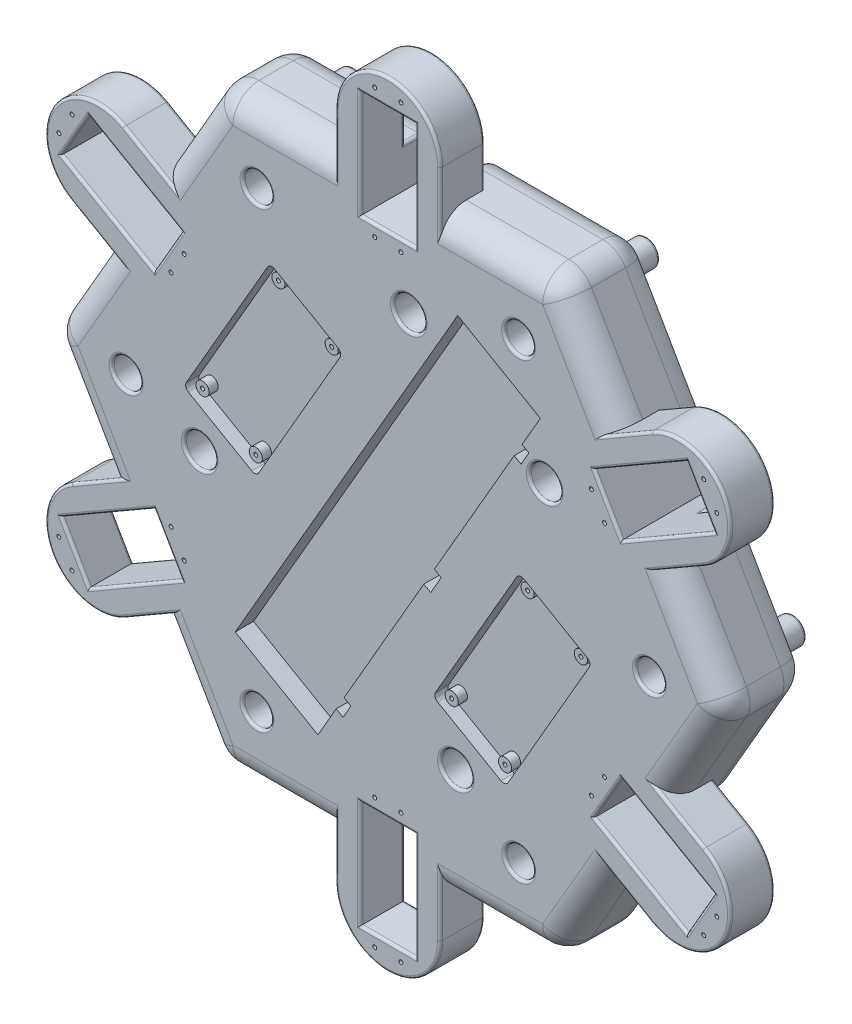
from build123d import *

# Parameters (mm, degrees)
MBODY_DEPTH              = 33
BOTTOMFLOOR_R            = 4.99999999999995
BOTTOMFLOOR_R_2          = 5.000000000000004
BOTTOMFLOOR_R_3          = 4.999999999999997
BOTTOMFLOOR_R_4          = 5.000000000000003
BOTTOMFLOOR_R_5          = 5
BODYBASE_DEPTH           = 10
SERVOCIRCLE_DEPTH        = 17
BBCUT_DEPTH              = 7
PCACUT_DEPTH             = 5
SKETCH10_R               = 2.4999999999999947
SKETCH10_R_2             = 0.7499999999999986
SKETCH10_R_3             = 2.499999999999995
SKETCH10_R_4             = 0.7499999999999987
SKETCH10_R_5             = 2.5000000000000093
SKETCH10_R_6             = 2.4999999999999956
SKETCH10_R_7             = 0.7500000000000021
SKETCH10_R_8             = 2.5000000000000226
SKETCH10_R_9             = 2.5000000000000027
PCAFIXTURE_DEPTH         = 3.5
HOLLOWBOTTOM_DEPTH       = 18
BOTTOMBATTCUT_DEPTH      = 2
SKETCH20_R               = 2.000000000000001
SKETCH20_R_2             = 2.0000000000000093
SKETCH20_R_3             = 0.8000000000000097
SKETCH20_R_4             = 2.0000000000000098
SKETCH20_R_5             = 2
SKETCH20_R_6             = 0.7999999999999977
SKETCH20_R_7             = 0.8000000000000015
SKETCH20_R_8             = 2.0000000000000036
BOTTOMBATTFIXTURE_DEPTH  = 3.45
SKETCH33_R               = 2.0000000000000004
SKETCH33_R_2             = 1.5000000000000004
SKETCH33_R_3             = 2.0000000000000027
SKETCH33_R_4             = 1.5000000000000042
SKETCH33_R_5             = 1.9999999999999962
SKETCH33_R_6             = 1.4999999999999973
SKETCH33_R_7             = 2
SKETCH33_R_8             = 1.5000000000000009
SKETCH33_R_9             = 2.000000000000001
SKETCH33_R_10            = 1.5
SKETCH33_R_11            = 2.0000000000000036
BOTTOMBATTFIXTURE1_DEPTH = 1.75
BOTTOMBATTFIXTURE2_R     = 0.8
SKETCH28_R               = 6.000000000000002
SKETCH28_R_2             = 5.999999999999995
SKETCH28_R_3             = 6.0000000000000036
SKETCH28_R_4             = 6.000000000000003
CABLEHOLES_DEPTH         = 15
SKETCH26_R               = 0.7499999999999987
SKETCH26_R_2             = 0.7500000000000004
SKETCH26_R_3             = 0.7499999999999996
SKETCH26_R_4             = 0.750000000000071
SKETCH26_R_5             = 0.7500000000000843
SKETCH26_R_6             = 0.7499999999999855
SKETCH26_R_7             = 0.7500000000000253
SERVOSCREWS_DEPTH        = 3
SKETCH34_R               = 5.499999999999997
SKETCH34_R_2             = 5.5000000000000036
CAPCUTIN_DEPTH           = 10
ROUNDEDGES10MM_R         = 10
ROUNDEDGES1MM_R          = 1


with BuildPart() as part:
    # HEXAGON → MBODY (new body)
    with BuildSketch(Plane.XY):
        Polygon((89.2544641670907, -39.28976590027362), (102.6778579257495, -47.039765900273636), (129.903810567666, 0.11696735998981134), (102.67785792574949, 47.273700620253294), (89.25446416709067, 39.52370062025329), (78.75446416709069, 57.710234099726506), (92.17785792574949, 65.46023409972649), (64.95190528383297, 112.61696735999004), (10.500000000000128, 112.61696735999004), (10.500000000000133, 97.11696735998862), (-10.499999999999867, 97.11696735998862), (-10.499999999999869, 112.61696735998996), (-64.95190528383303, 112.61696735999003), (-92.1778579257495, 65.46023409972655), (-78.75446416709069, 57.71023409972655), (-89.25446416709067, 39.523700620253315), (-102.67785792574949, 47.27370062025332), (-129.90381056766597, 0.11696735998988073), (-102.67785792574946, -47.03976590027361), (-89.25446416709066, -39.28976590027361), (-78.75446416709066, -57.47629937974685), (-92.17785792574945, -65.22629937974685), (-64.95190528383293, -112.38303264001033), (-10.5, -112.38303264001033), (-10.5, -96.88303264001036), (10.499999999999998, -96.88303264001036), (10.499999999999998, -112.38303264001036), (64.95190528383301, -112.38303264001033), (92.17785792574952, -65.22629937974683), (78.7544641670907, -57.47629937974684), align=None)
    extrude(amount=MBODY_DEPTH)

    # BottomFloor → BODYBASE (add)
    with BuildSketch(Plane.XY):
        with Locations((56.0184025919368, -96.90975208809282)):
            Circle(BOTTOMFLOOR_R)
        with Locations((112.03680518387344, 0.11696735998991731)):
            Circle(BOTTOMFLOOR_R_2)
        with Locations((56.01840259193674, 97.14368680807236)):
            Circle(BOTTOMFLOOR_R_3)
        with Locations((-56.01840259193689, 97.14368680807235)):
            Circle(BOTTOMFLOOR_R_4)
        with Locations((-112.03680518387344, 0.11696735998981622)):
            Circle(BOTTOMFLOOR_R_5)
        with Locations((-56.01840259193685, -96.90975208809306)):
            Circle(BOTTOMFLOOR_R_5)
    extrude(amount=-BODYBASE_DEPTH)

    # CircleBits → SERVOCIRCLE (add)
    with BuildSketch(Plane.XY.offset(33)):
        with BuildLine():
            Line((-87.42785792574936, -73.45354071569902), (-100.85125168440781, -81.20354071569884))
            ThreePointArc((-100.85125168440781, -81.20354071569884), (-128.17175976009673, -73.8830326400104), (-120.85125168440814, -46.562524564321514))
            Line((-120.85125168440814, -46.562524564321514), (-107.42785792574934, -38.812524564321514))
            Line((-107.42785792574934, -38.812524564321514), (-102.67785792574936, -47.039765900273636))
            Line((-102.67785792574936, -47.039765900273636), (-124.76150572225255, -59.789765900273636))
            Line((-124.76150572225255, -59.789765900273636), (-114.26150572225254, -77.97629937974686))
            Line((-114.26150572225254, -77.97629937974686), (-92.17785792574936, -65.22629937974686))
            Line((-92.17785792574936, -65.22629937974686), (-87.42785792574936, -73.45354071569902))
        make_face()
        with BuildLine():
            Line((-19.999999999999936, 112.61696735998987), (-19.999999999999993, 128.11696735998984))
            ThreePointArc((-19.999999999999993, 128.11696735998984), (1.22e-15, 148.11696735998984), (20.000000000000068, 128.11696735998984))
            Line((20.000000000000068, 128.11696735998984), (20.000000000000068, 112.61696735998986))
            Line((20.000000000000068, 112.61696735998986), (10.500000000000068, 112.61696735998986))
            Line((10.500000000000068, 112.61696735998986), (10.500000000000068, 138.11696735998987))
            Line((10.500000000000068, 138.11696735998987), (-10.499999999999932, 138.11696735998987))
            Line((-10.499999999999932, 138.11696735998987), (-10.499999999999932, 112.61696735998987))
            Line((-10.499999999999932, 112.61696735998987), (-19.999999999999936, 112.61696735998987))
        make_face()
        with BuildLine():
            Line((19.999999999999993, -112.3830326400103), (19.999999999999943, -127.88303264001027))
            ThreePointArc((19.999999999999943, -127.88303264001027), (-6.185e-14, -147.8830326400102), (-20.00000000000007, -127.88303264001021))
            Line((-20.00000000000007, -127.88303264001021), (-20.000000000000014, -112.38303264001021))
            Line((-20.000000000000014, -112.38303264001021), (-10.500000000000007, -112.38303264001021))
            Line((-10.500000000000007, -112.38303264001021), (-10.500000000000007, -137.88303264001024))
            Line((-10.500000000000007, -137.88303264001024), (10.499999999999993, -137.88303264001024))
            Line((10.499999999999993, -137.88303264001024), (10.499999999999993, -112.3830326400103))
            Line((10.499999999999993, -112.3830326400103), (19.999999999999993, -112.3830326400103))
        make_face()
        with BuildLine():
            Line((87.42785792574955, 73.68747543567869), (100.85125168440833, 81.43747543567869))
            ThreePointArc((100.85125168440833, 81.43747543567869), (128.1717597600971, 74.11696735998991), (120.8512516844083, 46.79645928430116))
            Line((120.8512516844083, 46.79645928430116), (107.42785792574952, 39.046459284301136))
            Line((107.42785792574952, 39.046459284301136), (102.67785792574954, 47.27370062025331))
            Line((102.67785792574954, 47.27370062025331), (124.76150572225272, 60.02370062025332))
            Line((124.76150572225272, 60.02370062025332), (114.26150572225272, 78.21023409972653))
            Line((114.26150572225272, 78.21023409972653), (92.17785792574954, 65.46023409972652))
            Line((92.17785792574954, 65.46023409972652), (87.42785792574955, 73.68747543567869))
        make_face()
        with BuildLine():
            Line((107.42785792574942, -38.81252456432151), (120.85125168440823, -46.56252456432153))
            ThreePointArc((120.85125168440823, -46.56252456432153), (128.17175976009705, -73.88303264001026), (100.85125168440831, -81.20354071569909))
            Line((100.85125168440831, -81.20354071569909), (87.4278579257495, -73.45354071569909))
            Line((87.4278579257495, -73.45354071569909), (92.1778579257495, -65.22629937974693))
            Line((92.1778579257495, -65.22629937974693), (114.26150572225269, -77.97629937974695))
            Line((114.26150572225269, -77.97629937974695), (124.76150572225269, -59.78976590027373))
            Line((124.76150572225269, -59.78976590027373), (102.67785792574944, -47.03976590027368))
            Line((102.67785792574944, -47.03976590027368), (107.42785792574942, -38.81252456432151))
        make_face()
        with BuildLine():
            Line((-107.42785792574952, 39.04645928430111), (-120.85125168440835, 46.79645928430102))
            ThreePointArc((-120.85125168440835, 46.79645928430102), (-128.17175976009716, 74.11696735998987), (-100.85125168440835, 81.43747543567858))
            Line((-100.85125168440835, 81.43747543567858), (-87.42785792574949, 73.68747543567865))
            Line((-87.42785792574949, 73.68747543567865), (-92.17785792574949, 65.46023409972648))
            Line((-92.17785792574949, 65.46023409972648), (-114.26150572225268, 78.21023409972648))
            Line((-114.26150572225268, 78.21023409972648), (-124.76150572225268, 60.023700620253265))
            Line((-124.76150572225268, 60.023700620253265), (-102.67785792574952, 47.27370062025327))
            Line((-102.67785792574952, 47.27370062025327), (-107.42785792574952, 39.04645928430111))
        make_face()
    extrude(amount=-SERVOCIRCLE_DEPTH)

    # Breadboard → BBCUT (cut)
    with BuildSketch(Plane.XY.offset(33)):
        Polygon((-26.695036380934436, -82.73715932167696), (-58.30496361906642, -64.48715932167694), (26.695036380933505, 82.73715932167754), (58.30496361906536, 64.48715932167761), (57.30496361906544, 62.75510851410884), (51.30496361906547, 52.36280366869556), (53.90303983041888, 50.86280366869551), (50.903039830418884, 45.66665124598888), (48.30496361906557, 47.166651245988874), (17.804963619065557, -5.660898384861907), (20.40303983041887, -7.160898384861906), (16.403039830418862, -14.089101615137446), (13.804963619065543, -12.589101615137446), (-16.695036380934457, -65.4166512459882), (-14.09696016958114, -66.9166512459882), (-17.096960169581134, -72.11280366869484), (-19.69503638093445, -70.61280366869484), (-25.695036380934447, -81.0051085141081), align=None)
    extrude(amount=-BBCUT_DEPTH, mode=Mode.SUBTRACT)

    # Sketch9 → PCACUT (cut)
    with BuildSketch(Plane.XY.offset(33)):
        with BuildLine():
            Line((76.22977209901313, -5.789194315122851), (51.981060793048876, 8.210805684877133))
            ThreePointArc((51.981060793048876, 8.210805684877133), (50.46342270284382, 8.410606529886401), (49.24900998547998, 7.478754877308253))
            Line((49.24900998547998, 7.478754877308253), (18.249009985479983, -46.21482015732691))
            ThreePointArc((18.249009985479983, -46.21482015732691), (18.049209140470715, -47.732458247531966), (18.981060793048865, -48.946870964895815))
            Line((18.981060793048865, -48.946870964895815), (43.22977209901312, -62.9468709648958))
            ThreePointArc((43.22977209901312, -62.9468709648958), (44.74741018921817, -63.146671809905065), (45.961822906582015, -62.21482015732691))
            Line((45.961822906582015, -62.21482015732691), (76.96182290658201, -8.521245122691747))
            ThreePointArc((76.96182290658201, -8.521245122691747), (77.16162375159128, -7.003607032486694), (76.22977209901313, -5.789194315122851))
        make_face()
        with BuildLine():
            Line((-43.25096482800967, 63.14561512150796), (-19.002253522045397, 49.14561512150795))
            ThreePointArc((-19.002253522045397, 49.14561512150795), (-18.070401869467247, 47.93120240414412), (-18.27020271447651, 46.41356431393908))
            Line((-18.27020271447651, 46.41356431393908), (-49.27020271447651, -7.280010720696112))
            ThreePointArc((-49.27020271447651, -7.280010720696112), (-50.48461543184036, -8.211862373274263), (-52.002253522045415, -8.012061528264995))
            Line((-52.002253522045415, -8.012061528264995), (-76.25096482800967, 5.9879384717349895))
            ThreePointArc((-76.25096482800967, 5.9879384717349895), (-77.18281648058782, 7.202351189098833), (-76.98301563557855, 8.719989279303887))
            Line((-76.98301563557855, 8.719989279303887), (-45.98301563557856, 62.41356431393906))
            ThreePointArc((-45.98301563557856, 62.41356431393906), (-44.768602918214725, 63.345415966517216), (-43.25096482800967, 63.14561512150796))
        make_face()
    extrude(amount=-PCACUT_DEPTH, mode=Mode.SUBTRACT)

    # Sketch10 → PCAFIXTURE (add)
    # profile 1 of 8: a face of its own
    with BuildSketch(Plane.XY.offset(28)):
        with Locations((51.92961795156345, 3.621704069738496)):
            Circle(SKETCH10_R)
        with Locations((51.92961795156345, 3.621704069738496)):
            Circle(SKETCH10_R_2, mode=Mode.SUBTRACT)
    # profile 2 of 8: a face of its own
    with BuildSketch(Plane.XY.offset(28)):
        with Locations((72.28121494049783, -8.128295930261444)):
            Circle(SKETCH10_R_3)
        with Locations((72.28121494049783, -8.128295930261444)):
            Circle(SKETCH10_R_4, mode=Mode.SUBTRACT)
    # profile 3 of 8: a face of its own
    with BuildSketch(Plane.XY.offset(28)):
        with Locations((43.28121494049798, -58.35776934975899)):
            Circle(SKETCH10_R_5)
        with Locations((43.28121494049798, -58.35776934975899)):
            Circle(SKETCH10_R_4, mode=Mode.SUBTRACT)
    # profile 4 of 8: a face of its own
    with BuildSketch(Plane.XY.offset(28)):
        with Locations((22.929617951563632, -46.607769349759046)):
            Circle(SKETCH10_R_6)
        with Locations((22.929617951563632, -46.607769349759046)):
            Circle(SKETCH10_R_7, mode=Mode.SUBTRACT)
    # profile 5 of 8: a face of its own
    with BuildSketch(Plane.XY.offset(28)):
        with Locations((-43.30240766949474, 58.55651350637013)):
            Circle(SKETCH10_R_8)
        with Locations((-43.30240766949474, 58.55651350637013)):
            Circle(SKETCH10_R_4, mode=Mode.SUBTRACT)
    # profile 6 of 8: a face of its own
    with BuildSketch(Plane.XY.offset(28)):
        with Locations((-22.950810680560394, 46.80651350637019)):
            Circle(SKETCH10_R_9)
        with Locations((-22.950810680560394, 46.80651350637019)):
            Circle(SKETCH10_R_7, mode=Mode.SUBTRACT)
    # profile 7 of 8: a face of its own
    with BuildSketch(Plane.XY.offset(28)):
        with Locations((-51.95081068056019, -3.4229599131273547)):
            Circle(SKETCH10_R)
        with Locations((-51.95081068056019, -3.4229599131273547)):
            Circle(SKETCH10_R_2, mode=Mode.SUBTRACT)
    # profile 8 of 8: a face of its own
    with BuildSketch(Plane.XY.offset(28)):
        with Locations((-72.30240766949456, 8.327040086872586)):
            Circle(SKETCH10_R_3)
        with Locations((-72.30240766949456, 8.327040086872586)):
            Circle(SKETCH10_R_4, mode=Mode.SUBTRACT)
    extrude(amount=PCAFIXTURE_DEPTH)

    # Sketch16 → HOLLOWBOTTOM (cut)
    with BuildSketch(Plane(origin=(0, 0, 0), x_dir=(-1, 0, 0), z_dir=(0, 0, -1))):
        Polygon((-47.63139720814698, -82.38303264001027), (-61.44709581221842, -58.45354071570012), (-81.44709581221603, -23.812524564322977), (-95.26279441628974, 0.11696735998733805), (-81.44709581221753, 24.04645928429881), (-61.447095812217526, 58.68747543567636), (-47.631397208145444, 82.61696735998763), (-20.000000000002, 82.61696735998763), (19.999999999997957, 82.61696735998763), (47.63139720813962, 82.61696735998763), (61.44709581221898, 58.68747543566809), (81.44709581222025, 24.046459284294578), (95.26279441628976, 0.1169673599921323), (81.44709581221639, -23.81252456432136), (61.447095812216375, -58.4535407156989), (47.63139720814422, -82.38303264001027), (19.999999999999986, -82.38303264001027), (-20.000000000000014, -82.38303264001027), align=None)
    extrude(amount=-HOLLOWBOTTOM_DEPTH, mode=Mode.SUBTRACT)

    # Sketch18 → BOTTOMBATTCUT (cut)
    with BuildSketch(Plane.XY.offset(18)):
        Polygon((31.330127018922223, 44.38233916434958), (37.82531754730558, 40.632339164349546), (40.325317547305666, 44.9624661832719), (47.253520777580846, 40.96246618327209), (44.75352077758081, 36.63233916434984), (58.609927238132016, 28.63233916434975), (61.109927238132066, 32.96246618327204), (68.03813046840776, 28.962466183271943), (65.53813046840783, 24.63233916434983), (72.03332099679096, 20.882339164349922), (30.033320996790515, -51.86379475354383), (23.538130468407225, -48.113794753543836), (21.038130468407743, -52.44392177246513), (14.109927238132228, -48.44392177246512), (16.60992723813217, -44.11379475354303), (2.7535207775811967, -36.11379475354306), (0.25352077758123864, -40.44392177246518), (-6.674682452694316, -36.44392177246516), (-4.174682452694489, -32.11379475354326), (-10.66987298107778, -28.363794753543267), align=None)
        Polygon((-68.83518633153189, -35.109072714694065), (3.9109475863609577, -77.10907271469407), (7.7859475863608, -70.39737583536494), (12.116074605282993, -72.89737583536494), (16.616074605282996, -65.10314720130499), (12.285947586360805, -62.603147201304985), (16.160947586360802, -55.8914503219756), (-56.585186331532036, -13.891450321975617), (-60.46018633153195, -20.60314720130487), (-64.79031335045416, -18.103147201304864), (-69.29031335045416, -25.897375835364816), (-64.96018633153197, -28.397375835364812), align=None)
        Polygon((-18.054073792036345, 72.84604467488785), (-11.558883263653051, 69.09604467488785), (-9.058883263652891, 73.42617169381033), (-2.130680033377228, 69.42617169381025), (-4.6306800333770175, 65.09604467488842), (9.225726427174312, 57.09604467488825), (11.725726427174106, 61.4261716938101), (18.65392965744913, 57.42617169381038), (16.153929657449925, 53.096044674889555), (22.64912018583219, 49.346044674890145), (-19.350879814168394, -23.400089243003805), (-25.846070342551684, -19.650089243003805), (-28.34607034255218, -23.98021626192686), (-35.27427357282713, -19.980216261927186), (-32.774273572826836, -15.650089243004476), (-46.63068003337692, -7.65008924300503), (-49.13068003337701, -11.980216261927398), (-56.058883263652525, -7.980216261927398), (-53.558883263652575, -3.6500892430052723), (-60.05407379203635, 0.09991075699500503), align=None)
    extrude(amount=BOTTOMBATTCUT_DEPTH, mode=Mode.SUBTRACT)

    # Sketch20 → BOTTOMBATTFIXTURE (cut)
    with BuildSketch(Plane(origin=(0, 0, 19.999999999999996), x_dir=(-1, 0, 0), z_dir=(0, 0, -1))):
        with Locations((0.6012840678326445, -17.9244871952779)):
            Circle(SKETCH20_R)
        with Locations((-61.96473208354549, 10.443031606083816)):
            Circle(SKETCH20_R_2)
        with Locations((-32.59871593216745, 39.57959961600894)):
            Circle(SKETCH20_R_3)
        with Locations((49.985484878790636, 10.539218315261165)):
            Circle(SKETCH20_R_4)
        with Locations((-12.58053127258731, 38.90673711662218)):
            Circle(SKETCH20_R_5)
        with Locations((16.785484878790562, 68.04330512654808)):
            Circle(SKETCH20_R_6)
        with Locations((-11.483208038020553, -56.94353288427496)):
            Circle(SKETCH20_R_7)
        with Locations((6.65335997190555, -67.25699015239469)):
            Circle(SKETCH20_R_5)
        with Locations((46.020878773266276, -23.743532884274803)):
            Circle(SKETCH20_R_8)
    extrude(amount=-BOTTOMBATTFIXTURE_DEPTH, mode=Mode.SUBTRACT)

    # Sketch33 → BOTTOMBATTFIXTURE1 (add)
    # profile 1 of 6: a face of its own
    with BuildSketch(Plane(origin=(0, 0, 19.999999999999996), x_dir=(1, 0, 0), z_dir=(0, 0, -1))):
        with Locations(Location((-0.6012840678326705, 17.92448719527759, 0), (0, 0, 180))):
            Circle(SKETCH33_R)
        with Locations(Location((-0.6012840678326705, 17.92448719527759, 0), (0, 0, 180))):
            Circle(SKETCH33_R_2, mode=Mode.SUBTRACT)
    # profile 2 of 6: a face of its own
    with BuildSketch(Plane(origin=(0, 0, 19.999999999999996), x_dir=(1, 0, 0), z_dir=(0, 0, -1))):
        with Locations(Location((61.96473208354549, -10.443031606083816, 0), (0, 0, 180))):
            Circle(SKETCH33_R_3)
        with Locations(Location((61.96473208354549, -10.443031606083816, 0), (0, 0, 180))):
            Circle(SKETCH33_R_4, mode=Mode.SUBTRACT)
    # profile 3 of 6: a face of its own
    with BuildSketch(Plane(origin=(0, 0, 19.999999999999996), x_dir=(1, 0, 0), z_dir=(0, 0, -1))):
        with Locations(Location((-49.985484878790636, -10.539218315261223, 0), (0, 0, 180))):
            Circle(SKETCH33_R_5)
        with Locations(Location((-49.985484878790636, -10.539218315261223, 0), (0, 0, 180))):
            Circle(SKETCH33_R_6, mode=Mode.SUBTRACT)
    # profile 4 of 6: a face of its own
    with BuildSketch(Plane(origin=(0, 0, 19.999999999999996), x_dir=(1, 0, 0), z_dir=(0, 0, -1))):
        with Locations(Location((12.580531272586379, -38.906737116620924, 0), (0, 0, 180))):
            Circle(SKETCH33_R_7)
        with Locations(Location((12.580531272586379, -38.906737116620924, 0), (0, 0, 180))):
            Circle(SKETCH33_R_8, mode=Mode.SUBTRACT)
    # profile 5 of 6: a face of its own
    with BuildSketch(Plane(origin=(0, 0, 19.999999999999996), x_dir=(1, 0, 0), z_dir=(0, 0, -1))):
        with Locations(Location((-6.653359971905553, 67.25699015239469, 0), (0, 0, 180))):
            Circle(SKETCH33_R_9)
        with Locations(Location((-6.653359971905553, 67.25699015239469, 0), (0, 0, 180))):
            Circle(SKETCH33_R_10, mode=Mode.SUBTRACT)
    # profile 6 of 6: a face of its own
    with BuildSketch(Plane(origin=(0, 0, 19.999999999999996), x_dir=(1, 0, 0), z_dir=(0, 0, -1))):
        with Locations(Location((-46.02087877326613, 23.743532884274778, 0), (0, 0, 180))):
            Circle(SKETCH33_R_11)
        with Locations(Location((-46.02087877326613, 23.743532884274778, 0), (0, 0, 180))):
            Circle(SKETCH33_R_4, mode=Mode.SUBTRACT)
    extrude(amount=-BOTTOMBATTFIXTURE1_DEPTH)

    # BOTTOMBATTFIXTURE2
    bottombattfixture2_edges = [part.edges().sort_by_distance(p)[0] for p in [
        (-5.153359971905553, -67.25699015239469, 19.999999999999996),
        (-48.485484878790636, 10.539218315261223, 19.999999999999996),
        (14.08053127258638, 38.906737116620924, 19.999999999999996),
        (63.4647320835455, 10.443031606083816, 19.999999999999996),
        (0.8987159321673299, -17.92448719527759, 19.999999999999996),
        (-44.520878773266126, -23.743532884274778, 19.999999999999996),
    ]]
    fillet(bottombattfixture2_edges, radius=BOTTOMBATTFIXTURE2_R)

    # Sketch28 → CABLEHOLES (cut)
    with BuildSketch(Plane(origin=(0, 0, 18), x_dir=(-1, 0, 0), z_dir=(0, 0, -1))):
        with Locations((-7.998485091222909, 73.97040032786995)):
            Circle(SKETCH28_R)
        with Locations((-59.95985793977355, 43.970487726296724)):
            Circle(SKETCH28_R_2)
        with Locations((-25.96831594123516, -67.90459004278999)):
            Circle(SKETCH28_R_3)
        with Locations((71.89255468640643, -11.404590042790021)):
            Circle(SKETCH28_R_4)
    extrude(amount=-CABLEHOLES_DEPTH, mode=Mode.SUBTRACT)

    # Sketch26 → SERVOSCREWS (cut)
    with BuildSketch(Plane.XY.offset(33)):
        with Locations((-125.69211368833544, -66.67790562108858)):
            Circle(SKETCH26_R)
        with Locations((-120.69211368833564, -75.33815965893257)):
            Circle(SKETCH26_R)
        with Locations((-82.82385620100752, -41.9279056210879)):
            Circle(SKETCH26_R)
        with Locations((-77.82385620100699, -50.588159658933186)):
            Circle(SKETCH26_R)
        with Locations((-5.000000000000011, -92.63303264001024)):
            Circle(SKETCH26_R_2)
        with Locations((4.999999999999998, -92.63303264001024)):
            Circle(SKETCH26_R_2)
        with Locations((-5.00000000000001, -142.13303264001027)):
            Circle(SKETCH26_R_3)
        with Locations((4.999999999999998, -142.13303264001027)):
            Circle(SKETCH26_R_2)
        with Locations((125.69211368833655, -66.67790562108807)):
            Circle(SKETCH26_R_4)
        with Locations((120.69211368833658, -75.33815965893244)):
            Circle(SKETCH26_R_5)
        with Locations((77.82385620100679, -50.588159658932476)):
            Circle(SKETCH26_R)
        with Locations((82.8238562010069, -41.92790562108793)):
            Circle(SKETCH26_R)
        with Locations((125.69211368833655, 66.91184034106773)):
            Circle(SKETCH26_R_6)
        with Locations((120.69211368833658, 75.57209437891201)):
            Circle(SKETCH26_R)
        with Locations((77.82385620100688, 50.82209437891208)):
            Circle(SKETCH26_R)
        with Locations((82.82385620100696, 42.16184034106755)):
            Circle(SKETCH26_R)
        with Locations((5.000000000000243, 92.86696735998923)):
            Circle(SKETCH26_R_2)
        with Locations((-4.9999999999997655, 92.86696735998923)):
            Circle(SKETCH26_R_2)
        with Locations((4.999999999999965, 142.3669673599893)):
            Circle(SKETCH26_R_2)
        with Locations((-4.9999999999997655, 142.3669673599893)):
            Circle(SKETCH26_R_2)
        with Locations((-125.69211368833666, 66.91184034106772)):
            Circle(SKETCH26_R_7)
        with Locations((-77.82385620100673, 50.8220943789121)):
            Circle(SKETCH26_R)
        with Locations((-82.82385620100679, 42.16184034106764)):
            Circle(SKETCH26_R)
        with Locations((-120.69211368833682, 75.57209437891179)):
            Circle(SKETCH26_R)
    extrude(amount=-SERVOSCREWS_DEPTH, mode=Mode.SUBTRACT)

    # Sketch34 → CAPCUTIN (cut)
    with BuildSketch(Plane.XY.offset(33)):
        with Locations((-49.94934309656473, 86.63176740792989)):
            Circle(SKETCH34_R)
        with Locations((49.94934309656473, 86.63176740792989)):
            Circle(SKETCH34_R)
        with Locations((100, 0)):
            Circle(SKETCH34_R_2)
        with Locations((50.05063980172955, -86.57328372793495)):
            Circle(SKETCH34_R)
        with Locations((-50.05063980172954, -86.57328372793496)):
            Circle(SKETCH34_R)
        with Locations((-100, 0)):
            Circle(SKETCH34_R_2)
    extrude(amount=-CAPCUTIN_DEPTH, mode=Mode.SUBTRACT)

    # ROUNDEDGES10MM
    roundedges10mm_edges = [part.edges().sort_by_distance(p)[0] for p in [
        (76.18988160479124, 93.15222139783435, 33),
        (-118.66583424670769, -19.347778602165835, 33),
        (42.47595264191651, -112.38303264001033, 33),
        (76.18988160479125, -92.9182866778547, 33),
        (118.66583424670775, 19.58171332214547, 33),
        (42.47595264191652, 112.61696735999004, 33),
        (-76.18988160479128, 93.15222139783435, 33),
        (-42.47595264191648, 112.61696735999003, 33),
        (-118.66583424670775, 19.581713322145497, 33),
        (-78.56488160479127, 89.03860072985829, 0),
        (-37.72595264191645, 112.61696735999003, 0),
        (37.72595264191655, 112.61696735999004, 0),
        (78.56488160479124, 89.03860072985827, 0),
        (116.29083424670775, 23.695333990121554, 0),
        (116.29083424670776, -23.46139927014191, 0),
        (78.56488160479127, -88.80466600987859, 0),
        (37.72595264191651, -112.38303264001033, 0),
        (-76.18988160479117, -92.9182866778547, 33),
        (-37.725952641916464, -112.38303264001033, 0),
        (-78.56488160479118, -88.80466600987859, 0),
        (71.44709581221835, -41.133032640011464, 0),
        (1.37845e-12, -82.38303264001027, 0),
        (-71.44709581221699, -41.13303264000907, 0),
        (-71.44709581221468, 41.36696735998988, 0),
        (2.91323e-12, 82.61696735998763, 0),
        (71.44709581221758, 41.36696735998748, 0),
        (-116.29083424670772, -23.46139927014186, 0),
        (-42.47595264191647, -112.38303264001033, 33),
        (-116.29083424670773, 23.695333990121604, 0),
        (-64.95190528383303, 112.61696735999003, 16.5),
        (64.95190528383297, 112.61696735999004, 16.5),
        (129.903810567666, 0.116967359989813, 16.5),
        (64.95190528383301, -112.38303264001033, 16.5),
        (-64.95190528383293, -112.38303264001033, 16.5),
        (-129.90381056766597, 0.11696735998988322, 16.5),
        (118.66583424670773, -19.347778602165864, 33),
    ]]
    fillet(roundedges10mm_edges, radius=ROUNDEDGES10MM_R)

    # ROUNDEDGES1MM
    roundedges1mm_edges = [part.edges().sort_by_distance(p)[0] for p in [
        (84.00446416709067, 48.6169673599899, 33),
        (-61.01840259193685, -96.90975208809306, -10),
        (51.01840259193685, -96.90975208809282, -10),
        (96.5079849446717, 67.96023409972652, 33),
        (-107.00798494467168, 49.773700620253294, 33),
        (10.5000000000001, 117.61696735998925, 33),
        (-92.17785792574949, 65.46023409972653, 13),
        (-10.49999999999987, 112.61696735998999, 13),
        (10.500000000000131, 112.61696735998933, 13),
        (1.3323e-13, 97.11696735998862, 33),
        (92.17785792574949, 65.46023409972649, 13),
        (102.67785792574898, 47.273700620252995, 13),
        (102.67785792574952, -47.039765900273636, 13),
        (92.17785792574952, -65.22629937974685, 13),
        (-10.4999999999999, 117.61696735998925, 33),
        (10.5, -112.38303264001034, 13),
        (-10.499999999999998, -112.38303264001034, 13),
        (-92.17785792574944, -65.22629937974685, 13),
        (-102.67785792574946, -47.03976590027361, 13),
        (-102.67785792574949, 47.27370062025332, 13),
        (128.1717597600971, 74.11696735998991, 16),
        (114.13955480507892, 42.92145928430115, 16),
        (113.71968182400113, 53.648700620253315, 16),
        (119.51150572225272, 69.11696735998993, 16),
        (103.21968182400113, 71.83523409972653, 16),
        (94.13955480507894, 77.56247543567869, 16),
        (128.1717597600971, 74.11696735998991, 33),
        (89.80942778615672, 75.06247543567868, 33),
        (-96.50798494467168, 67.9602340997265, 33),
        (119.51150572225272, 69.11696735998993, 33),
        (109.80942778615672, 40.42145928430113, 33),
        (-9.203e-14, -147.8830326400102, 16),
        (-20.000000000000043, -120.13303264001021, 16),
        (-10.500000000000007, -125.13303264001023, 16),
        (-7.11e-15, -137.88303264001024, 16),
        (10.499999999999993, -125.13303264001027, 16),
        (19.999999999999968, -120.13303264001028, 16),
        (-9.203e-14, -147.8830326400102, 33),
        (19.999999999999986, -115.1330326400103, 33),
        (-7.11e-15, -137.88303264001024, 33),
        (-20.00000000000002, -115.13303264001027, 33),
        (3.786e-14, 148.11696735998984, 16),
        (20.000000000000068, 120.36696735998984, 16),
        (10.500000000000068, 125.36696735998987, 16),
        (6.75e-14, 138.11696735998987, 16),
        (-10.499999999999932, 125.36696735998987, 16),
        (-19.999999999999964, 120.36696735998986, 16),
        (3.786e-14, 148.11696735998984, 33),
        (-19.999999999999947, 115.36696735998993, 33),
        (6.75e-14, 138.11696735998987, 33),
        (20.000000000000068, 115.36696735998994, 33),
        (-128.1717597600972, 74.11696735998983, 16),
        (-94.13955480507892, 77.5624754356786, 16),
        (-103.21968182400109, 71.83523409972648, 16),
        (-119.51150572225268, 69.11696735998987, 16),
        (-113.7196818240011, 53.648700620253265, 16),
        (-114.13955480507894, 42.921459284301065, 16),
        (-128.1717597600972, 74.11696735998983, 33),
        (-109.80942778615673, 40.42145928430109, 33),
        (-119.51150572225268, 69.11696735998987, 33),
        (-89.80942778615675, 75.06247543567865, 33),
        (128.17175976009705, -73.88303264001026, 16),
        (94.13955480507892, -77.32854071569909, 16),
        (103.2196818240011, -71.60129937974693, 16),
        (119.51150572225269, -68.88303264001034, 16),
        (113.71968182400107, -53.4147659002737, 16),
        (114.13955480507883, -42.68752456432152, 16),
        (128.17175976009705, -73.88303264001026, 33),
        (109.80942778615668, -40.18752456432153, 33),
        (119.51150572225269, -68.88303264001034, 33),
        (89.80942778615672, -74.82854071569908, 33),
        (-128.17175976009673, -73.88303264001038, 16),
        (-114.13955480507875, -42.687524564321514, 16),
        (-113.71968182400096, -53.414765900273636, 16),
        (-119.51150572225254, -68.88303264001024, 16),
        (-103.21968182400096, -71.60129937974686, 16),
        (-94.13955480507859, -77.32854071569892, 16),
        (-128.17175976009673, -73.88303264001038, 33),
        (-89.80942778615642, -74.82854071569895, 33),
        (-119.51150572225254, -68.88303264001024, 33),
        (-109.80942778615658, -40.187524564321535, 33),
        (-107.0079849446716, -49.53976590027362, 33),
        (-81.1360340274979, 59.08523409972655, 0),
        (-84.00446416709066, -48.38303264001023, 33),
        (1.3323e-13, 97.11696735998862, 0),
        (10.500000000000133, 99.86696735998933, 0),
        (84.00446416709067, 48.6169673599899, 0),
        (91.63603402749789, 40.898700620253294, 0),
        (-96.50798494467159, -67.72629937974685, 33),
        (84.0044641670907, -48.38303264001023, 0),
        (81.13603402749793, -58.85129937974685, 0),
        (-1.78e-15, -96.88303264001036, 0),
        (-10.5, -99.63303264001034, 0),
        (-81.13603402749787, -58.85129937974685, 0),
        (-84.00446416709066, -48.38303264001023, 0),
        (-91.6360340274979, 40.89870062025332, 0),
        (-84.00446416709067, 48.61696735998993, 0),
        (-10.500000000000004, -117.3830326400103, 33),
        (-1.78e-15, -96.88303264001036, 33),
        (10.499999999999996, -117.3830326400103, 33),
        (-84.00446416709067, 48.61696735998993, 33),
        (13.99848509122291, 73.97040032786995, 33),
        (13.99848509122291, 73.97040032786995, 18),
        (65.95985793977354, 43.970487726296724, 33),
        (65.95985793977354, 43.970487726296724, 18),
        (-65.89255468640643, -11.404590042790021, 33),
        (-65.89255468640643, -11.404590042790021, 18),
        (31.968315941235165, -67.90459004278999, 33),
        (31.968315941235165, -67.90459004278999, 18),
        (96.5079849446717, -67.72629937974689, 33),
        (84.0044641670907, -48.38303264001023, 33),
        (107.0079849446717, -49.53976590027368, 33),
        (-55.55063980172954, -86.57328372793496, 23),
        (-55.55063980172954, -86.57328372793496, 33),
        (-105.5, -1.77e-15, 23),
        (-105.5, -1.77e-15, 33),
        (-55.44934309656473, 86.63176740792989, 23),
        (-55.44934309656473, 86.63176740792989, 33),
        (44.44934309656473, 86.63176740792989, 23),
        (44.44934309656473, 86.63176740792989, 33),
        (94.5, -1.77e-15, 23),
        (94.5, -1.77e-15, 33),
        (44.55063980172955, -86.57328372793495, 23),
        (44.55063980172955, -86.57328372793495, 33),
        (-10.499999999999869, 99.86696735998933, 0),
        (81.1360340274979, 59.085234099726506, 0),
        (91.63603402749791, -40.66476590027363, 0),
        (10.499999999999998, -99.63303264001034, 0),
        (-91.63603402749787, -40.66476590027361, 0),
        (-100.14132824486308, 45.809234526186074, 2.9289321881345227),
        (-100.14132824486302, -45.575299806206345, 2.9289321881345227),
        (-89.64132824486308, 63.99576800565928, 2.9289321881345227),
        (-10.499999999999869, 109.6880351718555, 2.9289321881345227),
        (10.500000000000135, 109.68803517185552, 2.9289321881345227),
        (89.64132824486306, 63.995768005659244, 2.9289321881345227),
        (100.14132824486305, 45.809234526186046, 2.9289321881345263),
        (100.14132824486309, -45.57529980620638, 2.9289321881345227),
        (-10.499999999999993, -109.4541004518758, 2.928932188134521),
        (-89.64132824486302, -63.761833285679586, 2.9289321881345227),
        (89.6413282448631, -63.7618332856796, 2.9289321881345227),
        (10.499999999999998, -109.4541004518758, 2.928932188134521),
        (107.03680518387344, 0.11696735998991792, -10),
        (51.01840259193674, 97.14368680807236, -10),
        (107.0079849446717, 49.77370062025331, 33),
        (-61.01840259193689, 97.14368680807235, -10),
        (-117.03680518387344, 0.11696735998981683, -10),
    ]]
    fillet(roundedges1mm_edges, radius=ROUNDEDGES1MM_R)


solid = part.part
